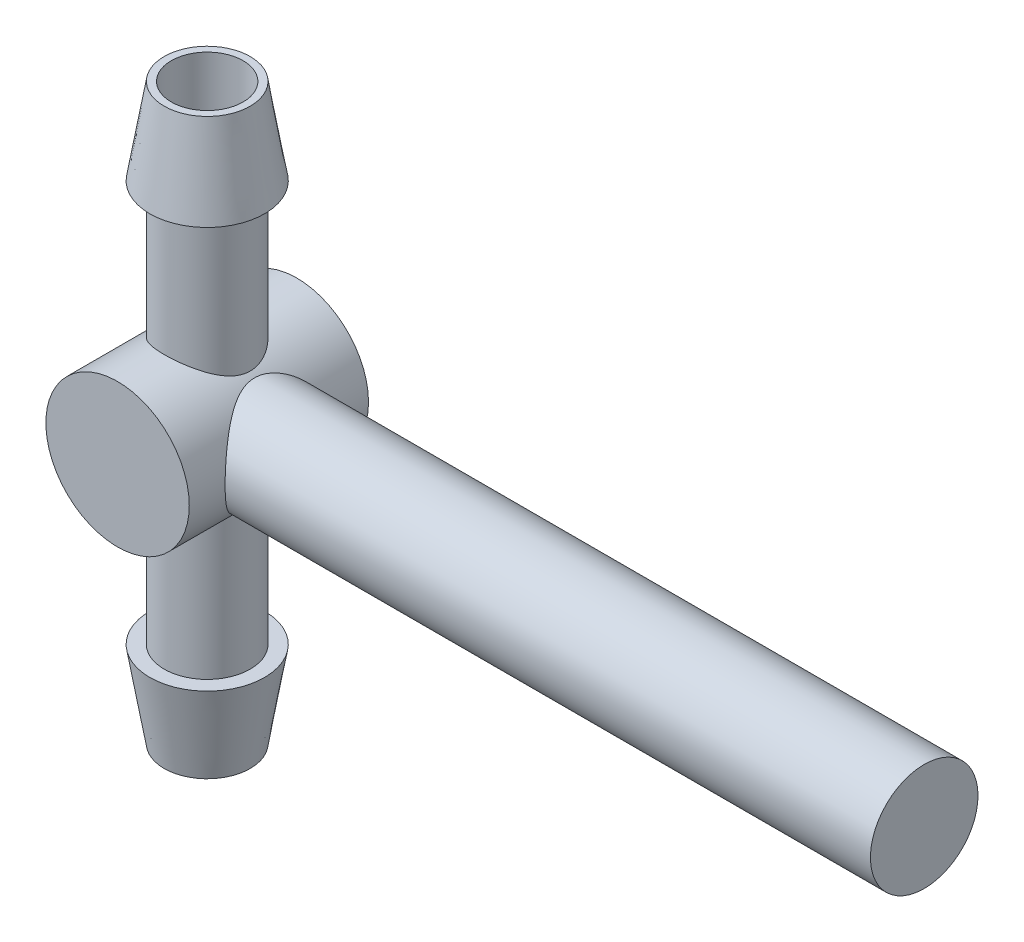
from build123d import *

# Parameters (mm, degrees)
SKETCH1_R           = 5
BOSS_EXTRUDE1_DEPTH = 6.25
SKETCH2_R           = 3
BOSS_EXTRUDE2_DEPTH = 20
SKETCH3_R           = 3.75
BOSS_EXTRUDE3_DEPTH = 50
SKETCH4_R           = 2.5
CUT_EXTRUDE1_DEPTH  = 40
CUT_EXTRUDE2_REACH  = 14.5
SKETCH5_R           = 3.75
SKETCH7_R           = 5
BOSS_EXTRUDE4_DEPTH = 2.5


with BuildPart() as part:
    # Sketch1 → Boss-Extrude1 (new body, symmetric)
    with BuildSketch(Plane.XY):
        Circle(SKETCH1_R)
    extrude(amount=BOSS_EXTRUDE1_DEPTH, both=True)

    # Sketch2 → Boss-Extrude2 (add, symmetric)
    with BuildSketch(Plane(origin=(0, 0, 0), x_dir=(1, 0, 0), z_dir=(0, 1, 0))):
        Circle(SKETCH2_R)
    extrude(amount=BOSS_EXTRUDE2_DEPTH, both=True)

    # Sketch3 → Boss-Extrude3 (add)
    with BuildSketch(Plane(origin=(0, 0, 0), x_dir=(0, 0, -1), z_dir=(1, 0, 0))):
        Circle(SKETCH3_R)
    extrude(amount=BOSS_EXTRUDE3_DEPTH)

    # Sketch4 → Cut-Extrude1 (cut)
    with BuildSketch(Plane.XZ.offset(20)):
        Circle(SKETCH4_R)
    extrude(amount=-CUT_EXTRUDE1_DEPTH, mode=Mode.SUBTRACT)

    # Sketch5 → Cut-Extrude2 (cut, up to next)
    with BuildSketch(Plane.XY.offset(6.25), mode=Mode.PRIVATE) as cut_extrude2_sk1:
        Circle(SKETCH5_R)
    cut_extrude2_tool1 = extrude(cut_extrude2_sk1.sketch, amount=-CUT_EXTRUDE2_REACH, mode=Mode.PRIVATE) & part.part
    add(cut_extrude2_tool1.solids().sort_by_distance((0, 0, 6.25))[0], mode=Mode.SUBTRACT)

    # Sketch6 → Revolve1 (revolve)
    with BuildSketch(Plane.XY):
        Polygon((3, 14), (3, 20), (4, 14), align=None)
        Polygon((3, -20), (4, -14), (3, -14), align=None)
    revolve(axis=Axis((0, 20, 0), (0, -1, 0)))

    # Sketch7 → Boss-Extrude4 (add)
    with BuildSketch(Plane.XY.offset(6.25)):
        Circle(SKETCH7_R)
    extrude(amount=-BOSS_EXTRUDE4_DEPTH)


solid = part.part
